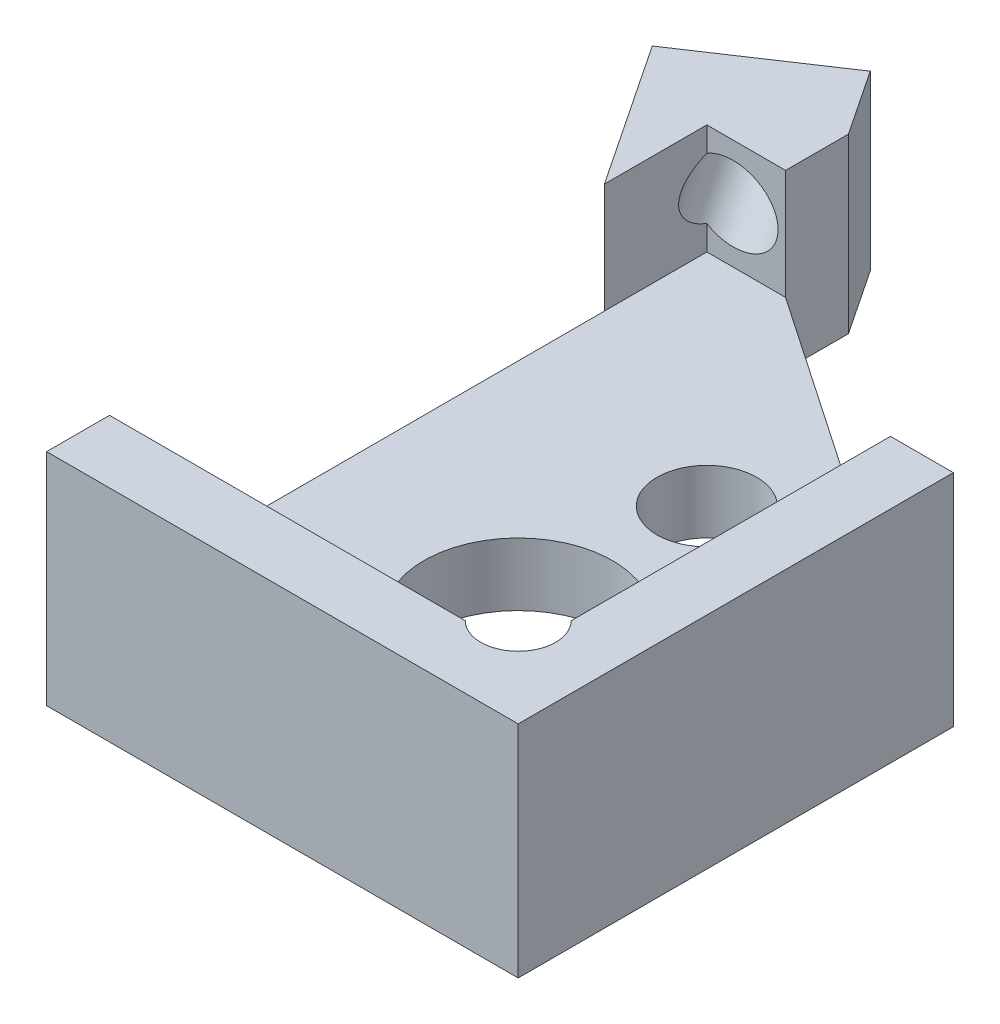
from build123d import *

# Parameters (mm, degrees)
SKETCH1_W                     = 8.5
SKETCH1_H                     = 11.5
BOSS_EXTRUDE1_DEPTH           = 3.5
SKETCH2_W                     = 6.5
SKETCH2_H                     = 9.5
CUT_EXTRUDE1_DEPTH            = 2.5
SKETCH3_R                     = 1.5
CUT_EXTRUDE2_DEPTH            = 2
SKETCH6_R                     = 0.5953125
CUT_EXTRUDE5_DEPTH            = 2.5
SKETCH7_R                     = 0.79375
CUT_EXTRUDE6_DEPTH            = 2
BOSS_EXTRUDE2_DEPTH           = 3.5
SKETCH14_W                    = 5.965258944
SKETCH14_H                    = 5.132960456
CUT_EXTRUDE8_DEPTH            = 0.75
TAP_DRILL_FOR_0_80_TAP1_D     = 1.19126
TAP_DRILL_FOR_0_80_TAP1_DEPTH = 7.11
TAP_DRILL_FOR_0_80_TAP1_TIP   = 0.357890611
CUT_EXTRUDE7_REACH            = 5.5


with BuildPart() as part:
    # Sketch1 → Boss-Extrude1 (new body)
    with BuildSketch(Plane(origin=(0, 0, 0), x_dir=(1, 0, 0), z_dir=(0, 1, 0))):
        Rectangle(SKETCH1_W, SKETCH1_H)
    extrude(amount=BOSS_EXTRUDE1_DEPTH)

    # Sketch2 → Cut-Extrude1 (cut)
    with BuildSketch(Plane(origin=(0, 3.5, 0), x_dir=(1, 0, 0), z_dir=(0, 1, 0))):
        Rectangle(SKETCH2_W, SKETCH2_H)
    extrude(amount=-CUT_EXTRUDE1_DEPTH, mode=Mode.SUBTRACT)

    # Sketch3 → Cut-Extrude2 (cut, through all)
    with BuildSketch(Plane(origin=(0, 1, 0), x_dir=(1, 0, 0), z_dir=(0, 1, 0))):
        with Locations((0.25, -1.75)):
            Circle(SKETCH3_R)
    extrude(amount=-CUT_EXTRUDE2_DEPTH, mode=Mode.SUBTRACT)

    # Sketch6 → Cut-Extrude5 (cut)
    with BuildSketch(Plane(origin=(0, 3.5, 0), x_dir=(1, 0, 0), z_dir=(0, 1, 0))):
        with Locations((2.829050494, -4.329050494)):
            Circle(SKETCH6_R)
    extrude(amount=-CUT_EXTRUDE5_DEPTH, mode=Mode.SUBTRACT)

    # Sketch7 → Cut-Extrude6 (cut, through all)
    with BuildSketch(Plane(origin=(0, 1, 0), x_dir=(1, 0, 0), z_dir=(0, 1, 0))):
        with Locations((0.25, 1.25)):
            Circle(SKETCH7_R)
        with Locations((-1.625, -3.5)):
            Circle(SKETCH7_R)
        with Locations((2.125, -3.5)):
            Circle(SKETCH7_R)
    extrude(amount=-CUT_EXTRUDE6_DEPTH, mode=Mode.SUBTRACT)

    # Sketch9 → Boss-Extrude2 (add)
    with BuildSketch(Plane(origin=(0, 3.5, 0), x_dir=(1, 0, 0), z_dir=(0, 1, 0))):
        Polygon((-2.69064642, 6.789569053), (-4.770772156, 5.402818562), (-4.001541387, 4.248972409), (-3.411634369, 4.642243754), (-2.511322669, 5.242451554), (-1.921415651, 5.635722899), align=None)
    extrude(amount=-BOSS_EXTRUDE2_DEPTH)

    # Sketch14 → Cut-Extrude8 (cut)
    with BuildSketch(Plane(origin=(0, 3.5, 0), x_dir=(1, 0, 0), z_dir=(0, 1, 0))):
        with Locations((-3.25, 4.75)):
            Rectangle(SKETCH14_W, SKETCH14_H)
    extrude(amount=-CUT_EXTRUDE8_DEPTH, mode=Mode.SUBTRACT)

    # Tap Drill for #0-80 Tap1
    with Locations(Plane(origin=(-3.961538462, 0, -5.942307692), x_dir=(-0.832050294, 0, 0.554700196), z_dir=(-0.554700196, 0, -0.832050294))):
        with Locations((-0.27742214, 1.875)):
            Hole(TAP_DRILL_FOR_0_80_TAP1_D / 2, depth=TAP_DRILL_FOR_0_80_TAP1_DEPTH)
            with Locations((0, 0, -(TAP_DRILL_FOR_0_80_TAP1_DEPTH + TAP_DRILL_FOR_0_80_TAP1_TIP / 2))):  # 118° drill point
                Cone(0, TAP_DRILL_FOR_0_80_TAP1_D / 2, TAP_DRILL_FOR_0_80_TAP1_TIP, mode=Mode.SUBTRACT)

    # Sketch13 → Cut-Extrude7 (cut, up to next)
    with BuildSketch(Plane(origin=(0, 3.5, 0), x_dir=(1, 0, 0), z_dir=(0, 1, 0)), mode=Mode.PRIVATE) as cut_extrude7_sk1:
        Polygon((-1.997600385, 5.75), (-1.997600385, 4.75), (3.25, 1.170806318), (4.25, 1.170806318), (4.25, 5.75), align=None)
    cut_extrude7_tool1 = extrude(cut_extrude7_sk1.sketch, amount=-CUT_EXTRUDE7_REACH, mode=Mode.PRIVATE) & part.part
    add(cut_extrude7_tool1.solids().sort_by_distance((1.797917, 3.5, -3.996239))[0], mode=Mode.SUBTRACT)
    # Sketch13 → Cut-Extrude7 (cut, up to next)
    with BuildSketch(Plane(origin=(0, 3.5, 0), x_dir=(1, 0, 0), z_dir=(0, 1, 0)), mode=Mode.PRIVATE) as cut_extrude7_sk2:
        Polygon((-4.25, 4.621660328), (-3.25, 3.121660328), (-3.25, -5.75), (-4.25, -5.75), align=None)
    cut_extrude7_tool2 = extrude(cut_extrude7_sk2.sketch, amount=-CUT_EXTRUDE7_REACH, mode=Mode.PRIVATE) & part.part
    add(cut_extrude7_tool2.solids().sort_by_distance((-3.762992, 3.5, 0.929426))[0], mode=Mode.SUBTRACT)


solid = part.part
